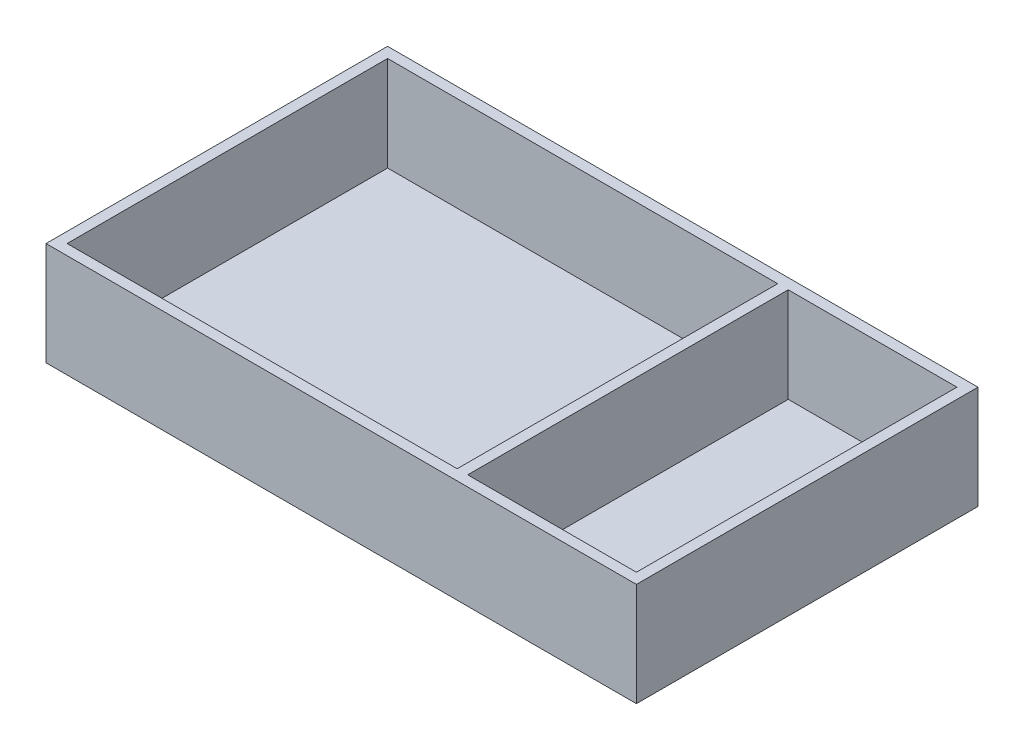
from build123d import *

# Parameters (mm, degrees)
CROQUIS1_W              = 280
CROQUIS1_H              = 162
CROQUIS1_W_2            = 270
CROQUIS1_H_2            = 152
SALIENTE_EXTRUIR1_DEPTH = 45
CROQUIS3_W              = 280
CROQUIS3_H              = 162
SALIENTE_EXTRUIR2_DEPTH = 4
CROQUIS4_W              = 5
CROQUIS4_H              = 152
SALIENTE_EXTRUIR3_DEPTH = 45


with BuildPart() as part:
    # Croquis1 → Saliente-Extruir1 (new body)
    with BuildSketch(Plane(origin=(0, 0, 0), x_dir=(1, 0, 0), z_dir=(0, 1, 0))):
        Rectangle(CROQUIS1_W, CROQUIS1_H)
        Rectangle(CROQUIS1_W_2, CROQUIS1_H_2, mode=Mode.SUBTRACT)
    extrude(amount=SALIENTE_EXTRUIR1_DEPTH)

    # Croquis3 → Saliente-Extruir2 (add)
    with BuildSketch(Plane.XZ):
        Rectangle(CROQUIS3_W, CROQUIS3_H)
    extrude(amount=SALIENTE_EXTRUIR2_DEPTH)

    # Croquis4 → Saliente-Extruir3 (add)
    with BuildSketch(Plane(origin=(0, 0, 0), x_dir=(1, 0, 0), z_dir=(0, 1, 0))):
        with Locations((52.5, 0)):
            Rectangle(CROQUIS4_W, CROQUIS4_H)
    extrude(amount=SALIENTE_EXTRUIR3_DEPTH)


solid = part.part
